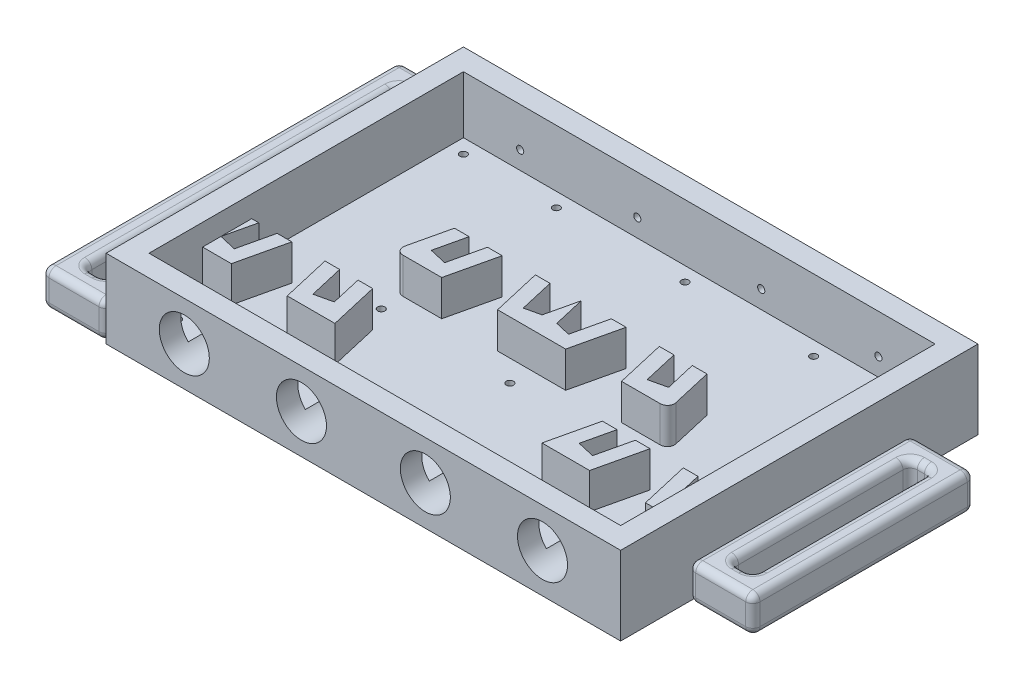
from build123d import *

# Parameters (mm, degrees)
SKETCH1_W             = 72
SKETCH1_H             = 50
BOSS_EXTRUDE2_DEPTH   = 11
SKETCH2_W             = 66
SKETCH2_H             = 44
CUT_EXTRUDE1_DEPTH    = 8
BOSS_EXTRUDE3_DEPTH   = 5
SKETCH4_R             = 3.5
CUT_EXTRUDE3_DEPTH    = 10
SKETCH10_R            = 3.5
CUT_EXTRUDE9_DEPTH    = 1.5
SKETCH6_R             = 0.5
CUT_EXTRUDE5_DEPTH    = 1.5
SKETCH8_W             = 9
SKETCH8_H             = 50
SKETCH8_W_2           = 3
SKETCH8_H_2           = 44
BOSS_EXTRUDE4_DEPTH   = 5
SKETCH8_H_3           = 31
SKETCH8_H_4           = 25
BOSS_EXTRUDE4_2_DEPTH = 5
FILLET1_R             = 1
FILLET2_R             = 1
FILLET3_R             = 1
SKETCH11_R            = 0.5
CUT_EXTRUDE10_DEPTH   = 3


with BuildPart() as part:
    # Sketch1 → Boss-Extrude2 (new body)
    with BuildSketch(Plane(origin=(0, 0, 0), x_dir=(1, 0, 0), z_dir=(0, 1, 0))):
        with Locations((36, 25)):
            Rectangle(SKETCH1_W, SKETCH1_H)
    extrude(amount=BOSS_EXTRUDE2_DEPTH)

    # Sketch2 → Cut-Extrude1 (cut)
    with BuildSketch(Plane(origin=(0, 11, 0), x_dir=(1, 0, 0), z_dir=(0, 1, 0))):
        with Locations((36, 25)):
            Rectangle(SKETCH2_W, SKETCH2_H)
    extrude(amount=-CUT_EXTRUDE1_DEPTH, mode=Mode.SUBTRACT)

    # Sketch3 → Boss-Extrude3 (add)
    with BuildSketch(Plane(origin=(0, 3, 0), x_dir=(1, 0, 0), z_dir=(0, 1, 0))):
        Polygon((3, 13.062377636), (3, 10.5), (7.026796995, 10.5), (8.613288649, 17.371850324), (6.560680434, 17.371850324), (5.435925162, 12.5), align=None)
        Polygon((13.256603848, 17.371850324), (14.843095502, 10.5), (21.514072203, 10.5), (19.927580549, 17.371850324), (17.874972333, 17.371850324), (18.869892498, 13.062377636), (16.433967336, 12.5), (15.309212064, 17.371850324), align=None)
        Polygon((18.337883744, 30.409361369), (16.75139209, 23.537511045), (23.422368791, 23.537511045), (25.008860445, 30.409361369), (22.956252229, 30.409361369), (21.831496957, 25.537511045), (19.395571795, 26.099888681), (20.39049196, 30.409361369), align=None)
        Polygon((37.027719315, 26.032403365), (37.603710592, 23.537511045), (40.762205291, 23.537511045), (42.348696945, 30.409361369), (40.29608873, 30.409361369), (39.171333458, 25.537511045), align=None)
        Polygon((46.993969971, 30.409361369), (48.580461625, 23.537511045), (55.251438325, 23.537511045), (53.664946671, 30.409361369), (51.612338456, 30.409361369), (52.60725862, 26.099888681), (50.171333458, 25.537511045), (49.046578186, 30.409361369), align=None)
        Polygon((52.070461625, 17.371850324), (50.483969971, 10.5), (57.154946671, 10.5), (58.741438325, 17.371850324), (56.68883011, 17.371850324), (55.564074838, 12.5), (53.128149676, 13.062377636), (54.12306984, 17.371850324), align=None)
        Polygon((63.386711351, 17.371850324), (64.973203005, 10.5), (69, 10.5), (69, 13.062377636), (66.564074838, 12.5), (65.439319566, 17.371850324), align=None)
        Polygon((29.65413347, 30.409361369), (31.240625124, 23.537511045), (34.399119823, 23.537511045), (34.9751111, 26.032403365), (32.831496957, 25.537511045), (31.706741686, 30.409361369), align=None)
        Polygon((34.9751111, 26.032403365), (34.399119823, 23.537511045), (37.603710592, 23.537511045), (37.027719315, 26.032403365), (36.017218938, 30.409361369), (35.985611477, 30.409361369), align=None)
        Polygon((3, 17.371850324), (3, 13.062377636), (3.994920164, 17.371850324), align=None)
        Polygon((68.005079836, 17.371850324), (69, 13.062377636), (69, 17.371850324), align=None)
    extrude(amount=BOSS_EXTRUDE3_DEPTH)

    # Sketch4 → Cut-Extrude3 (cut)
    with BuildSketch(Plane.XY):
        with Locations((10.94, 5.5)):
            Circle(SKETCH4_R)
        with Locations((27.33, 5.5)):
            Circle(SKETCH4_R)
        with Locations((44.67, 5.5)):
            Circle(SKETCH4_R)
        with Locations((61.06, 5.5)):
            Circle(SKETCH4_R)
    extrude(amount=-CUT_EXTRUDE3_DEPTH, mode=Mode.SUBTRACT)

    # Sketch10 → Cut-Extrude9 (cut)
    with BuildSketch(Plane.XY.offset(-50)):
        with Locations((10.94, 5.5)):
            Circle(SKETCH10_R)
        with Locations((27.33, 5.5)):
            Circle(SKETCH10_R)
        with Locations((44.67, 5.5)):
            Circle(SKETCH10_R)
        with Locations((61.06, 5.5)):
            Circle(SKETCH10_R)
    extrude(amount=CUT_EXTRUDE9_DEPTH, mode=Mode.SUBTRACT)

    # Sketch6 → Cut-Extrude5 (cut)
    with BuildSketch(Plane.XY.offset(-48.5)):
        with Locations((10.94, 5.5)):
            Circle(SKETCH6_R)
        with Locations((27.33, 5.5)):
            Circle(SKETCH6_R)
        with Locations((44.67, 5.5)):
            Circle(SKETCH6_R)
        with Locations((61.06, 5.5)):
            Circle(SKETCH6_R)
    extrude(amount=CUT_EXTRUDE5_DEPTH, mode=Mode.SUBTRACT)

    # Fillet3
    fillet3_edges = [part.edges().sort_by_distance(p)[0] for p in [
        (16.75139209, 5.5, -23.537511045),
        (55.251438325, 5.5, -23.537511045),
    ]]
    fillet(fillet3_edges, radius=FILLET3_R)

    # Sketch11 → Cut-Extrude10 (cut)
    with BuildSketch(Plane(origin=(0, 3, 0), x_dir=(1, 0, 0), z_dir=(0, 1, 0))):
        with Locations((5, 45)):
            Circle(SKETCH11_R)
        with Locations((18, 45)):
            Circle(SKETCH11_R)
        with Locations((36, 45)):
            Circle(SKETCH11_R)
        with Locations((54, 45)):
            Circle(SKETCH11_R)
        with Locations((67, 45)):
            Circle(SKETCH11_R)
        with Locations((5, 5)):
            Circle(SKETCH11_R)
        with Locations((18, 5)):
            Circle(SKETCH11_R)
        with Locations((36, 5)):
            Circle(SKETCH11_R)
        with Locations((54, 5)):
            Circle(SKETCH11_R)
        with Locations((67, 5)):
            Circle(SKETCH11_R)
        with Locations((18, 20.5)):
            Circle(SKETCH11_R)
        with Locations((36, 20.5)):
            Circle(SKETCH11_R)
        with Locations((54, 20.5)):
            Circle(SKETCH11_R)
    extrude(amount=-CUT_EXTRUDE10_DEPTH, mode=Mode.SUBTRACT)


with BuildPart() as body_2:
    # Sketch8 → Boss-Extrude4 (new body)
    with BuildSketch(Plane(origin=(0, 0, 0), x_dir=(-1, 0, 0), z_dir=(0, -1, 0))):
        with Locations((4.5, 25)):
            Rectangle(SKETCH8_W, SKETCH8_H)
        with Locations((4.5, 25)):
            Rectangle(SKETCH8_W_2, SKETCH8_H_2, mode=Mode.SUBTRACT)
    extrude(amount=-BOSS_EXTRUDE4_DEPTH)

    # Fillet2
    fillet2_edges = [body_2.edges().sort_by_distance(p)[0] for p in [
        (-9, 5, -25),
        (-4.5, 5, -50),
        (-3, 5, -25),
        (-3, 2.5, -3),
        (-4.5, 5, -47),
        (-3, 2.5, -47),
        (-6, 5, -25),
        (-6, 2.5, -47),
        (-4.5, 5, -3),
        (-6, 2.5, -3),
        (-3, 0, -25),
        (-4.5, 0, -3),
        (-6, 0, -25),
        (-4.5, 0, -47),
        (0, 5, -25),
        (-4.5, 0, -50),
        (-9, 0, -25),
        (-4.5, 0, 0),
        (0, 0, -25),
        (-4.5, 5, 0),
        (0, 2.5, -50),
        (-9, 2.5, -50),
        (-9, 2.5, 0),
        (0, 2.5, 0),
    ]]
    fillet(fillet2_edges, radius=FILLET2_R)


with BuildPart() as body_3:
    # Sketch8 → Boss-Extrude4 2 (new body)
    with BuildSketch(Plane(origin=(0, 0, 0), x_dir=(-1, 0, 0), z_dir=(0, -1, 0))):
        with Locations((-76.5, 25)):
            Rectangle(SKETCH8_W, SKETCH8_H_3)
        with Locations((-76.5, 25)):
            Rectangle(SKETCH8_W_2, SKETCH8_H_4, mode=Mode.SUBTRACT)
    extrude(amount=-BOSS_EXTRUDE4_2_DEPTH)

    # Fillet1
    fillet1_edges = [body_3.edges().sort_by_distance(p)[0] for p in [
        (81, 5, -25),
        (76.5, 5, -9.5),
        (78, 5, -25),
        (78, 2.5, -12.5),
        (76.5, 5, -37.5),
        (78, 2.5, -37.5),
        (75, 5, -25),
        (75, 2.5, -37.5),
        (76.5, 5, -12.5),
        (75, 2.5, -12.5),
        (78, 0, -25),
        (76.5, 0, -12.5),
        (75, 0, -25),
        (76.5, 0, -37.5),
        (72, 5, -25),
        (76.5, 0, -9.5),
        (81, 0, -25),
        (76.5, 0, -40.5),
        (72, 0, -25),
        (76.5, 5, -40.5),
        (72, 2.5, -9.5),
        (81, 2.5, -9.5),
        (81, 2.5, -40.5),
        (72, 2.5, -40.5),
    ]]
    fillet(fillet1_edges, radius=FILLET1_R)


solid = Compound([part.part, body_2.part, body_3.part])
